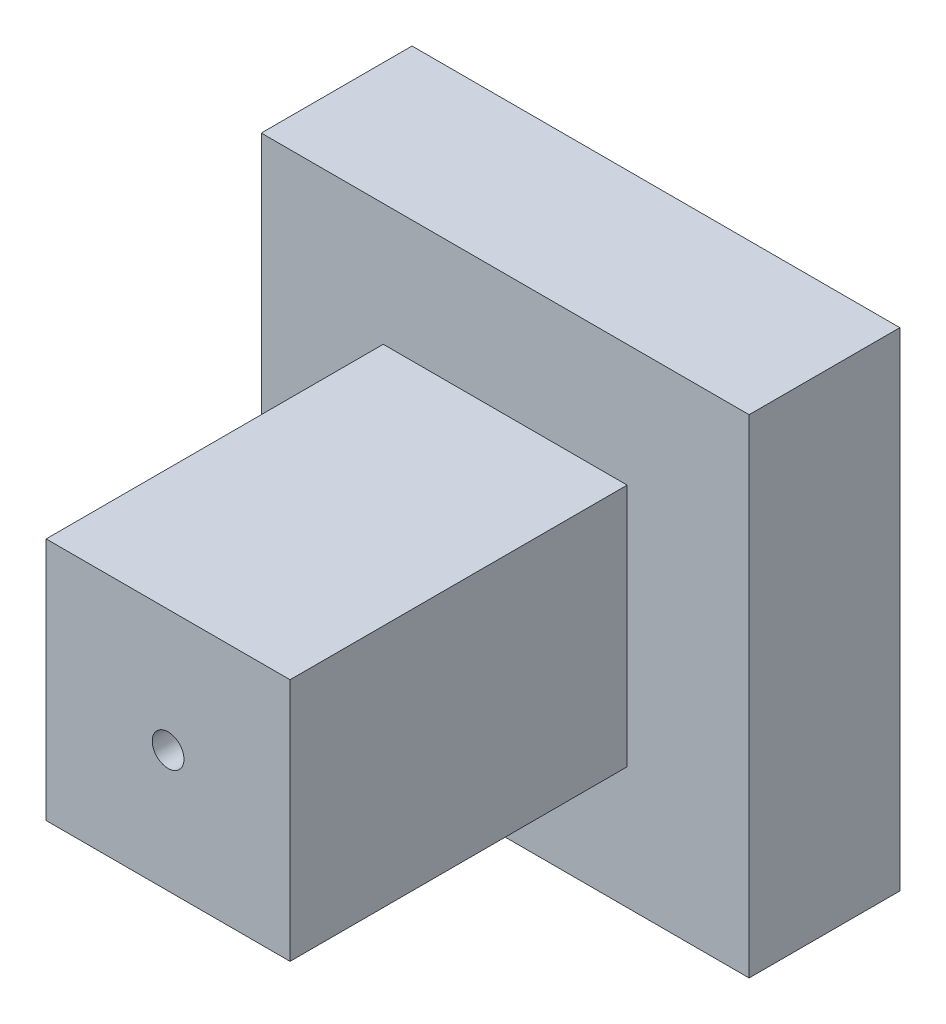
from build123d import *

# Parameters (mm, degrees)
SKETCH_1_W          = 100
SKETCH_1_H          = 100
EXTRUDE_2_DEPTH     = 138.2
SKETCH_1_4_W        = 200
SKETCH_1_4_H        = 200
EXTRUDE_3_DEPTH     = 61.8
SKETCH_1_5_R        = 6.5
CUT_EXTRUDE_1_DEPTH = 177.8


with BuildPart() as part:
    # 草图1 → 凸台-拉伸2 (new body)
    with BuildSketch(Plane.XY):
        with Locations((-2.376531009, -11.802029242)):
            Rectangle(SKETCH_1_W, SKETCH_1_H)
    extrude(amount=EXTRUDE_2_DEPTH)

    # 草图1<4> → 凸台-拉伸3 (add)
    with BuildSketch(Plane.XY):
        with Locations((-2.376531009, -11.802029242)):
            Rectangle(SKETCH_1_4_W, SKETCH_1_4_H)
    extrude(amount=-EXTRUDE_3_DEPTH)

    # 草图1<5> → 切除-拉伸1 (cut)
    with BuildSketch(Plane.XY):
        with Locations((-2.376531009, -11.802029242)):
            Circle(SKETCH_1_5_R)
    extrude(amount=CUT_EXTRUDE_1_DEPTH, mode=Mode.SUBTRACT)


solid = part.part
